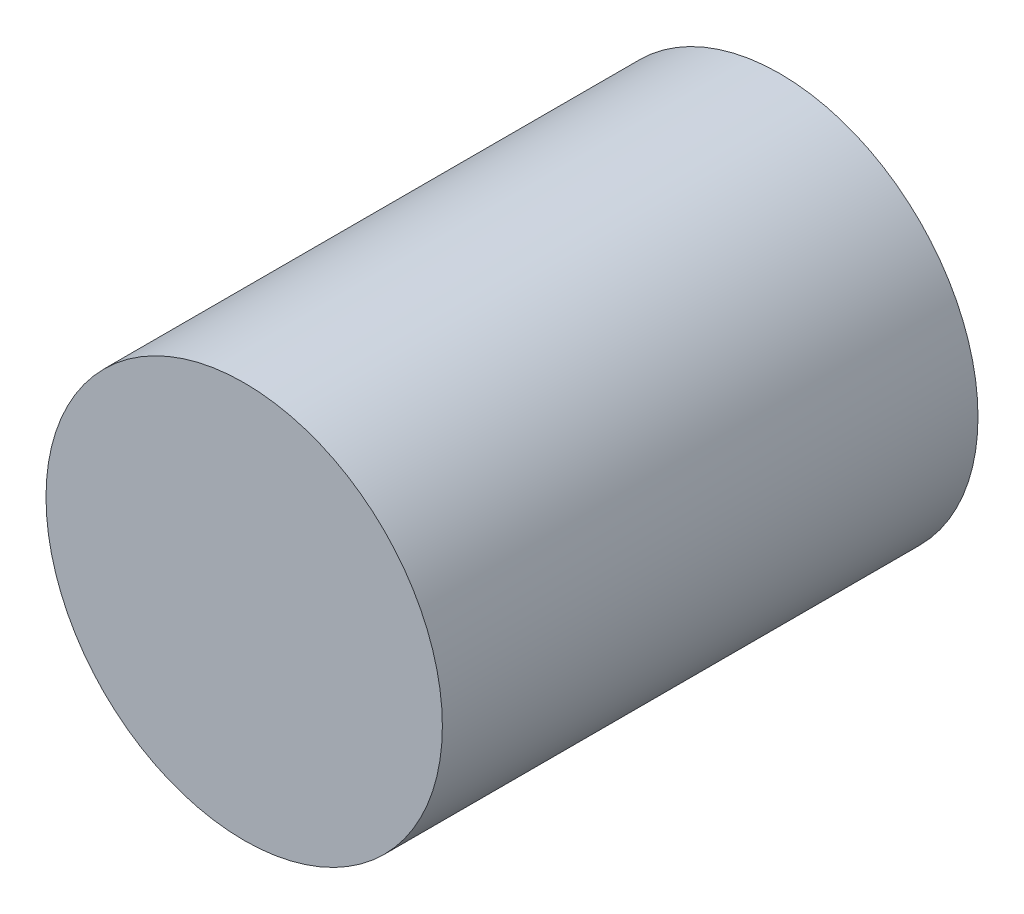
from build123d import *

# Parameters (mm, degrees)
SKETCH1_R          = 4.699
BASE_EXTRUDE_DEPTH = 12.7


with BuildPart() as part:
    # Sketch1 → Base-Extrude (new body)
    with BuildSketch(Plane.XY):
        Circle(SKETCH1_R)
    extrude(amount=BASE_EXTRUDE_DEPTH)


solid = part.part
